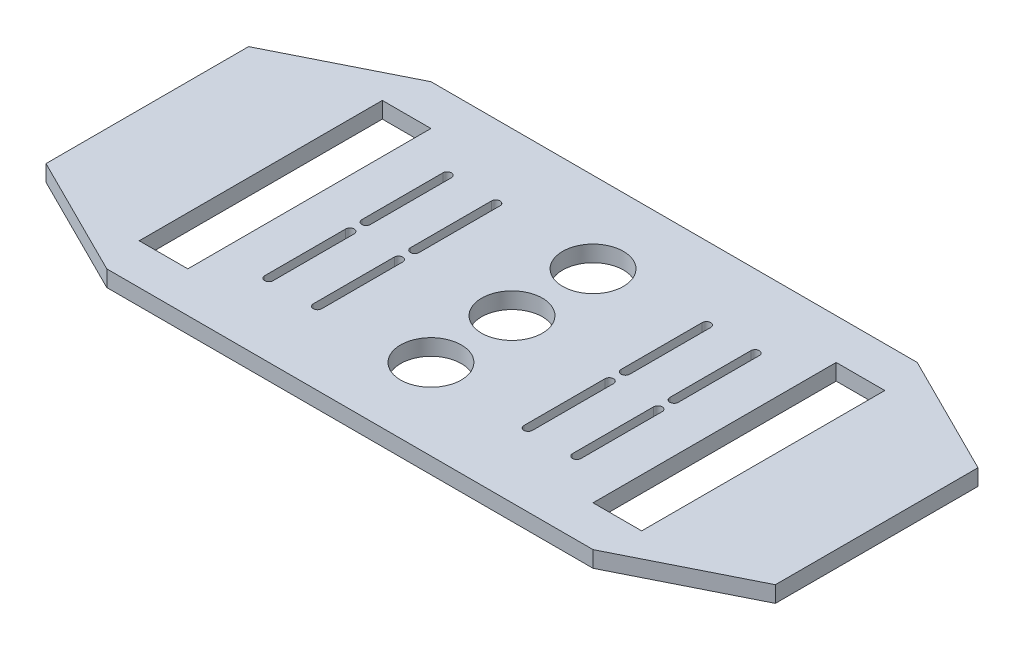
from build123d import *

# Parameters (mm, degrees)
ESQUISSE1_W                         = 180
ESQUISSE1_H                         = 80
BOSS_EXTRU_1_DEPTH                  = 4
ENL_V_MAT_EXTRU_1_DEPTH             = 4
ENL_V_MAT_EXTRU_2_DEPTH             = 4
ENL_V_MAT_EXTRU_5_REACH             = 6
ESQUISSE11_W                        = 12
ESQUISSE11_H                        = 60
ENL_V_MAT_EXTRU_5_DIRECTION_2_DEPTH = 1
ENL_V_MAT_EXTRU_6_REACH             = 6
ESQUISSE14_R                        = 7.5


with BuildPart() as part:
    # Esquisse1 → Boss.-Extru.1 (new body)
    with BuildSketch(Plane(origin=(0, 0, 0), x_dir=(1, 0, 0), z_dir=(0, 1, 0))):
        with Locations((90, 40)):
            Rectangle(ESQUISSE1_W, ESQUISSE1_H)
    extrude(amount=BOSS_EXTRU_1_DEPTH)

    # Esquisse2 → Enlèv. mat.-Extru.1 (cut)
    with BuildSketch(Plane(origin=(0, 4, 0), x_dir=(1, 0, 0), z_dir=(0, 1, 0))):
        Polygon((30, 0), (0, 15), (0, 0), align=None)
        Polygon((30, 80), (0, 65), (0, 80), align=None)
        Polygon((150, 0), (180, 15), (180, 0), align=None)
        Polygon((150, 80), (180, 80), (180, 65), align=None)
    extrude(amount=-ENL_V_MAT_EXTRU_1_DEPTH, mode=Mode.SUBTRACT)

    # Esquisse3 → Enlèv. mat.-Extru.2 (cut)
    with BuildSketch(Plane(origin=(0, 4, 0), x_dir=(1, 0, 0), z_dir=(0, 1, 0))):
        with BuildLine():
            Line((65.05, 38), (65.05, 18))
            ThreePointArc((65.05, 18), (64, 16.95), (62.95, 18))
            Line((62.95, 18), (62.95, 38))
            ThreePointArc((62.95, 38), (64, 39.05), (65.05, 38))
        make_face()
        with BuildLine():
            Line((50.95, 18), (50.95, 38))
            ThreePointArc((50.95, 38), (52, 39.05), (53.05, 38))
            Line((53.05, 38), (53.05, 18))
            ThreePointArc((53.05, 18), (52, 16.95), (50.95, 18))
        make_face()
        with BuildLine():
            Line((129.05, 18), (129.05, 38))
            ThreePointArc((129.05, 38), (128, 39.05), (126.95, 38))
            Line((126.95, 38), (126.95, 18))
            ThreePointArc((126.95, 18), (128, 16.95), (129.05, 18))
        make_face()
        with BuildLine():
            Line((114.95, 38), (114.95, 18))
            ThreePointArc((114.95, 18), (116, 16.95), (117.05, 18))
            Line((117.05, 18), (117.05, 38))
            ThreePointArc((117.05, 38), (116, 39.05), (114.95, 38))
        make_face()
        with BuildLine():
            Line((50.95, 62), (50.95, 42))
            ThreePointArc((50.95, 42), (52, 40.95), (53.05, 42))
            Line((53.05, 42), (53.05, 62))
            ThreePointArc((53.05, 62), (52, 63.05), (50.95, 62))
        make_face()
        with BuildLine():
            Line((65.05, 42), (65.05, 62))
            ThreePointArc((65.05, 62), (64, 63.05), (62.95, 62))
            Line((62.95, 62), (62.95, 42))
            ThreePointArc((62.95, 42), (64, 40.95), (65.05, 42))
        make_face()
        with BuildLine():
            Line((114.95, 42), (114.95, 62))
            ThreePointArc((114.95, 62), (116, 63.05), (117.05, 62))
            Line((117.05, 62), (117.05, 42))
            ThreePointArc((117.05, 42), (116, 40.95), (114.95, 42))
        make_face()
        with BuildLine():
            Line((129.05, 62), (129.05, 42))
            ThreePointArc((129.05, 42), (128, 40.95), (126.95, 42))
            Line((126.95, 42), (126.95, 62))
            ThreePointArc((126.95, 62), (128, 63.05), (129.05, 62))
        make_face()
    extrude(amount=-ENL_V_MAT_EXTRU_2_DEPTH, mode=Mode.SUBTRACT)

    # Esquisse11 → Enlèv. mat.-Extru.5 (cut, up to next)
    with BuildSketch(Plane(origin=(0, 4, 0), x_dir=(1, 0, 0), z_dir=(0, 1, 0)), mode=Mode.PRIVATE) as enl_v_mat_extru_5_sk1:
        with Locations((34, 40)):
            Rectangle(ESQUISSE11_W, ESQUISSE11_H)
    enl_v_mat_extru_5_tool1 = extrude(enl_v_mat_extru_5_sk1.sketch, amount=-ENL_V_MAT_EXTRU_5_REACH, mode=Mode.PRIVATE) & part.part
    add(enl_v_mat_extru_5_tool1.solids().sort_by_distance((34, 4, -40))[0], mode=Mode.SUBTRACT)
    # Esquisse11 → Enlèv. mat.-Extru.5 (cut, up to next)
    with BuildSketch(Plane(origin=(0, 4, 0), x_dir=(1, 0, 0), z_dir=(0, 1, 0)), mode=Mode.PRIVATE) as enl_v_mat_extru_5_sk2:
        with Locations((146, 40)):
            Rectangle(ESQUISSE11_W, ESQUISSE11_H)
    enl_v_mat_extru_5_tool2 = extrude(enl_v_mat_extru_5_sk2.sketch, amount=-ENL_V_MAT_EXTRU_5_REACH, mode=Mode.PRIVATE) & part.part
    add(enl_v_mat_extru_5_tool2.solids().sort_by_distance((146, 4, -40))[0], mode=Mode.SUBTRACT)

    # Esquisse11 → Enlèv. mat.-Extru.5 direction 2 (cut)
    with BuildSketch(Plane(origin=(0, 4, 0), x_dir=(1, 0, 0), z_dir=(0, 1, 0))):
        with Locations((34, 40)):
            Rectangle(ESQUISSE11_W, ESQUISSE11_H)
        with Locations((146, 40)):
            Rectangle(ESQUISSE11_W, ESQUISSE11_H)
    extrude(amount=ENL_V_MAT_EXTRU_5_DIRECTION_2_DEPTH, mode=Mode.SUBTRACT)

    # Esquisse14 → Enlèv. mat.-Extru.6 (cut, up to next)
    with BuildSketch(Plane(origin=(0, 4, 0), x_dir=(1, 0, 0), z_dir=(0, 1, 0)), mode=Mode.PRIVATE) as enl_v_mat_extru_6_sk1:
        with Locations((90, 60)):
            Circle(ESQUISSE14_R)
    enl_v_mat_extru_6_tool1 = extrude(enl_v_mat_extru_6_sk1.sketch, amount=-ENL_V_MAT_EXTRU_6_REACH, mode=Mode.PRIVATE) & part.part
    add(enl_v_mat_extru_6_tool1.solids().sort_by_distance((90, 4, -60))[0], mode=Mode.SUBTRACT)
    # Esquisse14 → Enlèv. mat.-Extru.6 (cut, up to next)
    with BuildSketch(Plane(origin=(0, 4, 0), x_dir=(1, 0, 0), z_dir=(0, 1, 0)), mode=Mode.PRIVATE) as enl_v_mat_extru_6_sk2:
        with Locations((90, 40)):
            Circle(ESQUISSE14_R)
    enl_v_mat_extru_6_tool2 = extrude(enl_v_mat_extru_6_sk2.sketch, amount=-ENL_V_MAT_EXTRU_6_REACH, mode=Mode.PRIVATE) & part.part
    add(enl_v_mat_extru_6_tool2.solids().sort_by_distance((90, 4, -40))[0], mode=Mode.SUBTRACT)
    # Esquisse14 → Enlèv. mat.-Extru.6 (cut, up to next)
    with BuildSketch(Plane(origin=(0, 4, 0), x_dir=(1, 0, 0), z_dir=(0, 1, 0)), mode=Mode.PRIVATE) as enl_v_mat_extru_6_sk3:
        with Locations((90, 20)):
            Circle(ESQUISSE14_R)
    enl_v_mat_extru_6_tool3 = extrude(enl_v_mat_extru_6_sk3.sketch, amount=-ENL_V_MAT_EXTRU_6_REACH, mode=Mode.PRIVATE) & part.part
    add(enl_v_mat_extru_6_tool3.solids().sort_by_distance((90, 4, -20))[0], mode=Mode.SUBTRACT)


solid = part.part
